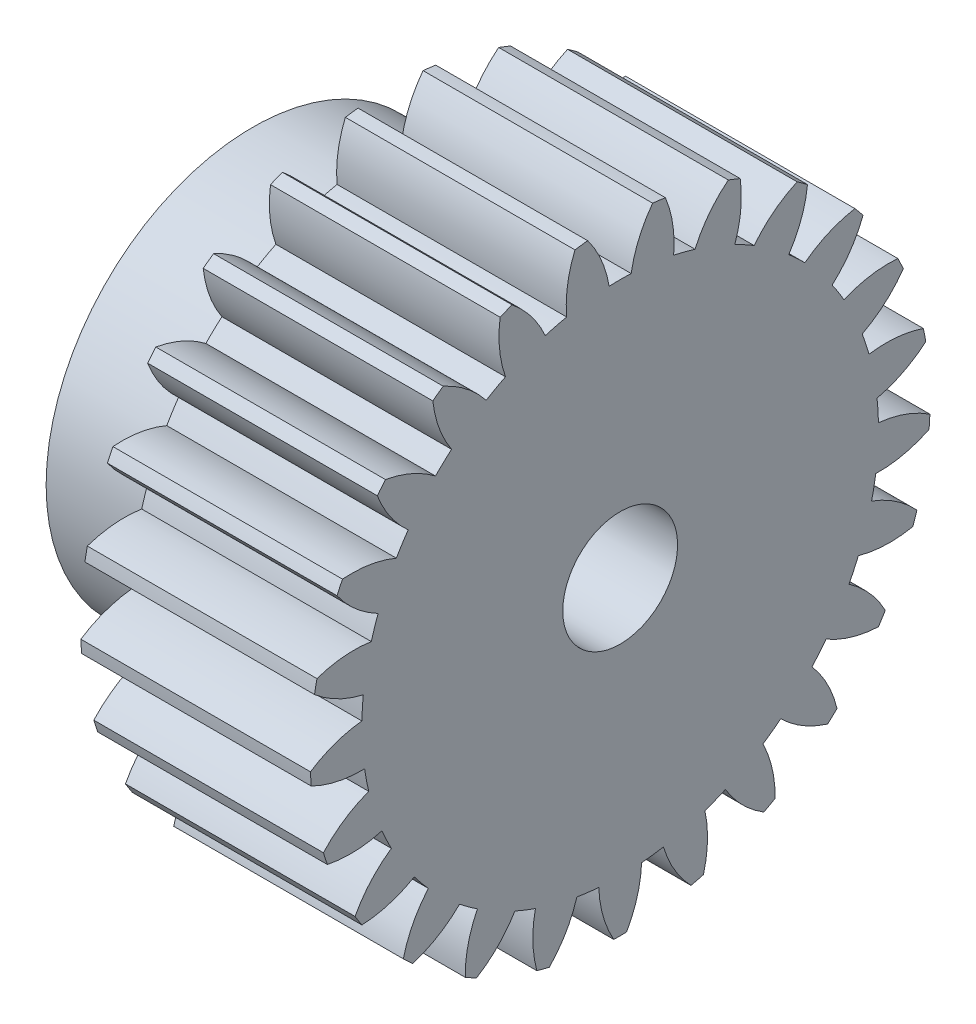
from build123d import *

# Parameters (mm, degrees)
BASPROSKE_W      = 10
BASPROSKE_H      = 13.5
TOOTHCUT_DEPTH   = 22.552262062
TEETHCUTS_COUNT  = 25
TEETHCUTS_ANGLE  = 345.6
HUBNEAONESKE_R   = 9
HUBNEARONE_DEPTH = 6.0000508
BORSKE_R         = 2.5
BORE_DEPTH       = 16.0000508


with BuildPart() as part:
    # BasProSke → Base-Revolve (revolve)
    with BuildSketch(Plane(origin=(0, 0, 0), x_dir=(1, 0, 0), z_dir=(0, 1, 0)), mode=Mode.PRIVATE) as base_revolve_sk:
        with Locations((5, 6.75)):
            Rectangle(BASPROSKE_W, BASPROSKE_H)
    revolve(base_revolve_sk.sketch.rotate(Axis((-10, 0, 0), (1, 0, 0)), 180), axis=Axis((-10, 0, 0), (1, 0, 0)))

    # TooCutSke → ToothCut (cut, through all)
    with BuildSketch(Plane(origin=(0, 0, 0), x_dir=(0, 0, -1), z_dir=(1, 0, 0))):
        with BuildLine():
            ThreePointArc((0.480087995, 11.238750665), (0, 11.249), (-0.480087995, 11.238750665))
            ThreePointArc((-0.480087995, 11.238750665), (-0.821124963, 12.40220054), (-1.432168974, 13.449361962))
            ThreePointArc((-1.432168974, 13.449361962), (0, 13.5254), (1.432168974, 13.449361962))
            ThreePointArc((1.432168974, 13.449361962), (0.821124963, 12.40220054), (0.480087995, 11.238750665))
        make_face()
    toothcut = extrude(amount=TOOTHCUT_DEPTH, mode=Mode.SUBTRACT)

    # TeethCuts: ToothCut ×25 about axis
    teethcuts_axis = Axis((-10, 0, 0), (1, 0, 0))
    for i in range(1, TEETHCUTS_COUNT):
        add(toothcut.rotate(teethcuts_axis, i * TEETHCUTS_ANGLE / (TEETHCUTS_COUNT - 1)), mode=Mode.SUBTRACT)

    # HubNeaOneSke → HubNearOne (add)
    with BuildSketch(Plane.ZY):
        with Locations(Location((0, 0, 0), (0, 0, 180))):
            Circle(HUBNEAONESKE_R)
    extrude(amount=HUBNEARONE_DEPTH)

    # BorSke → Bore (cut, symmetric)
    with BuildSketch(Plane(origin=(0, 0, 0), x_dir=(0, 0, -1), z_dir=(1, 0, 0))):
        with Locations(Location((0, 0, 0), (0, 0, 180))):
            Circle(BORSKE_R)
    extrude(amount=BORE_DEPTH, both=True, mode=Mode.SUBTRACT)


solid = part.part
